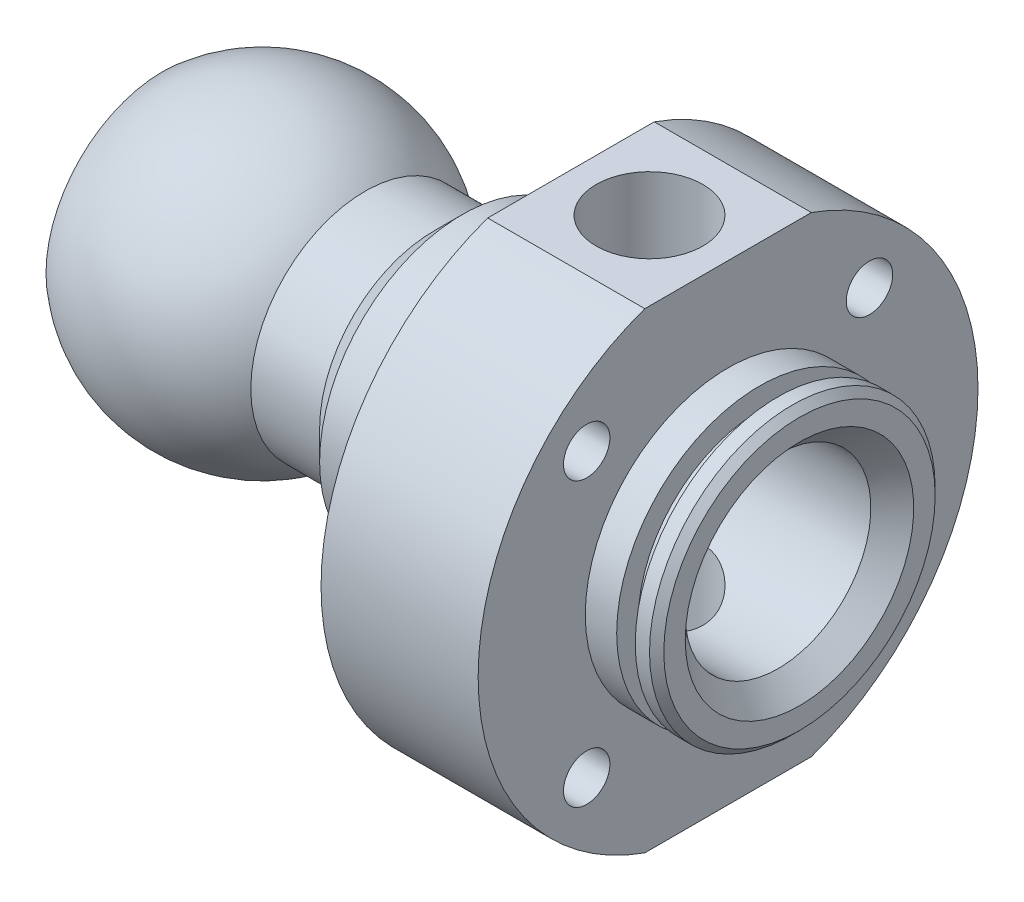
from build123d import *

# Parameters (mm, degrees)
ESQUISSE2_OUTSIDE_W          = 117.85
ESQUISSE2_OUTSIDE_H          = 98.65
ESQUISSE2_OUTSIDE_W_2        = 105
ESQUISSE2_OUTSIDE_H_2        = 66
ENL_V_MAT_EXTRU_1_DEPTH      = 50
ESQUISSE3_R                  = 7.475
ENL_V_MAT_EXTRU_2_DEPTH      = 67
ESQUISSE4_R                  = 3.25
ENL_V_MAT_EXTRU_3_DEPTH      = 80.2
R_P_TITION_CIRCULAIRE1_COUNT = 4
CHANFREIN1_SIZE              = 1


with BuildPart() as part:
    # Esquisse1 → Base-Révolution (revolve)
    with BuildSketch(Plane.XY):
        with BuildLine():
            Line((39.1, 16), (39.1, 20))
            Line((39.1, 20), (36.1, 20))
            Line((36.1, 20), (36.1, 17))
            Line((36.1, 17), (33.5, 17))
            Line((33.5, 17), (33.5, 20))
            Line((33.5, 20), (29.1, 20))
            Line((29.1, 20), (29.1, 35))
            Line((29.1, 35), (7.1, 35))
            Line((7.1, 35), (7.1, 20))
            Line((7.1, 20), (-8.1, 20))
            Line((-8.1, 20), (-12.1, 16))
            Line((-12.1, 16), (-21.738593384, 16))
            ThreePointArc((-21.738593384, 16), (-35.859578061, 21.498655709), (-50.1, 16.317168872))
            Line((-50.1, 16.317168872), (-50.1, 10))
            Line((-50.1, 10), (-47.1, 10))
            Line((-47.1, 10), (-47.1, 13.25))
            Line((-47.1, 13.25), (-43.1, 13.25))
            Line((-43.1, 13.25), (-43.1, 10))
            Line((-43.1, 10), (-29, 10))
            Line((-29, 10), (-28.9, 10.1))
            Line((-28.9, 10.1), (8.2, 10.1))
            Line((8.2, 10.1), (11.1, 13))
            Line((11.1, 13), (36.1, 13))
            Line((36.1, 13), (39.1, 16))
        make_face()
    revolve(axis=Axis((-69, 0, 0), (1, 0, 0)))

    # Esquisse2 outside → Enlèv. mat.-Extru.1 (cut, symmetric)
    with BuildSketch(Plane.XY):
        with Locations((-5.5, 0)):
            Rectangle(ESQUISSE2_OUTSIDE_W, ESQUISSE2_OUTSIDE_H)
        with Locations((-7.5, 0)):
            Rectangle(ESQUISSE2_OUTSIDE_W_2, ESQUISSE2_OUTSIDE_H_2, mode=Mode.SUBTRACT)
    extrude(amount=ENL_V_MAT_EXTRU_1_DEPTH, both=True, mode=Mode.SUBTRACT)

    # Esquisse3 → Enlèv. mat.-Extru.2 (cut, through all)
    with BuildSketch(Plane(origin=(0, 33, 0), x_dir=(-1, 0, 0), z_dir=(0, 1, 0))):
        with Locations((-18.1, 0)):
            Circle(ESQUISSE3_R)
    extrude(amount=-ENL_V_MAT_EXTRU_2_DEPTH, mode=Mode.SUBTRACT)

    # Esquisse4 → Enlèv. mat.-Extru.3 (cut, through all)
    with BuildSketch(Plane(origin=(29.1, 0, 0), x_dir=(0, 0, -1), z_dir=(1, 0, 0))):
        with Locations((19.798989873, -19.798989873)):
            Circle(ESQUISSE4_R)
    enl_v_mat_extru_3 = extrude(amount=-ENL_V_MAT_EXTRU_3_DEPTH, mode=Mode.SUBTRACT)

    # Répétition circulaire1: Enlèv. mat.-Extru.3 ×4 about axis
    r_p_tition_circulaire1_axis = Axis((-69, 0, 0), (1, 0, 0))
    for i in range(1, R_P_TITION_CIRCULAIRE1_COUNT):
        add(enl_v_mat_extru_3.rotate(r_p_tition_circulaire1_axis, i * 360 / R_P_TITION_CIRCULAIRE1_COUNT), mode=Mode.SUBTRACT)

    # Chanfrein1
    chanfrein1_edges = [part.edges().sort_by_distance(p)[0] for p in [
        (39.1, -20, 0),
    ]]
    chamfer(chanfrein1_edges, length=CHANFREIN1_SIZE)


solid = part.part
